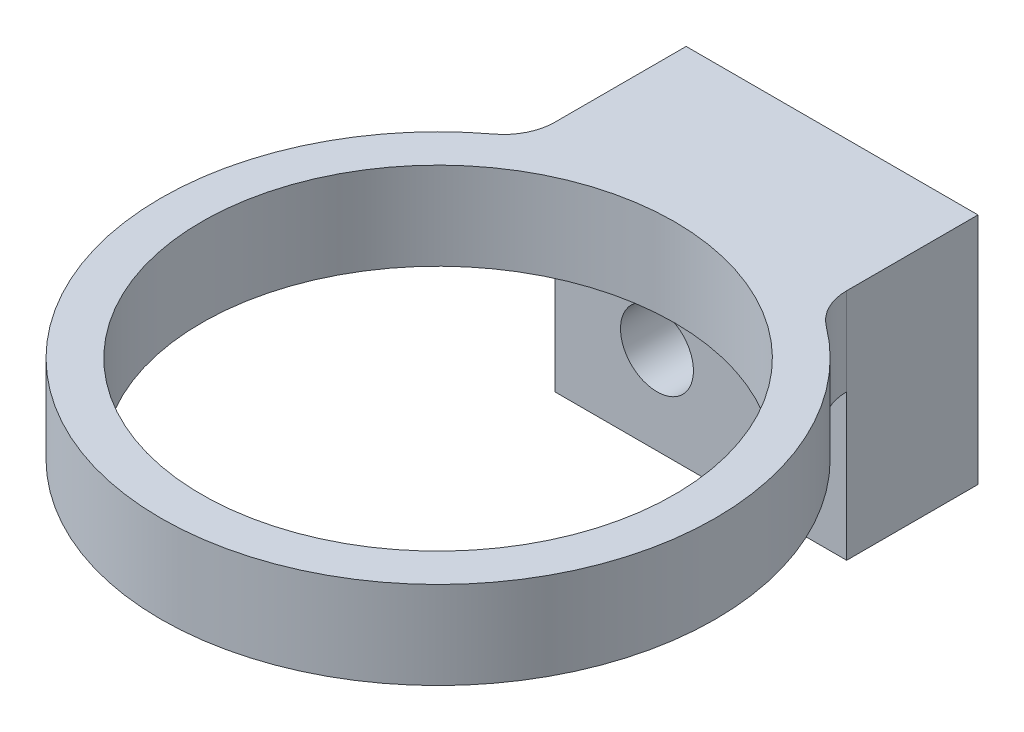
from build123d import *

# Parameters (mm, degrees)
BOSS_EXTRUDE1_DEPTH            = 3
SKETCH2_W                      = 10
SKETCH2_H                      = 4.5
BOSS_EXTRUDE2_DEPTH            = 5
F_1_6_1_6_DIAMETER_HOLE1_D     = 1.6
F_1_6_1_6_DIAMETER_HOLE1_DEPTH = 4
F_1_6_1_6_DIAMETER_HOLE1_TIP   = 0.480688495
F_2_5_2_5_DIAMETER_HOLE1_D     = 2.5
F_2_5_2_5_DIAMETER_HOLE1_DEPTH = 4.5
M14_CLEARANCE_HOLE1_D          = 16.2
M14_CLEARANCE_HOLE1_DEPTH      = 3
FILLET1_R                      = 1.749999932


with BuildPart() as part:
    # Sketch1 → Boss-Extrude1 (new body)
    with BuildSketch(Plane.XZ):
        with BuildLine():
            Line((-5, 5.422252789), (-5, 0))
            Line((-5, 0), (5, 0))
            Line((5, 0), (5, 5.422252789))
            ThreePointArc((5, 5.422252789), (0, 23), (-5, 5.422252789))
        make_face()
    extrude(amount=-BOSS_EXTRUDE1_DEPTH)

    # Sketch2 → Boss-Extrude2 (add)
    with BuildSketch(Plane.XZ):
        with Locations((0, 2.25)):
            Rectangle(SKETCH2_W, SKETCH2_H)
    extrude(amount=BOSS_EXTRUDE2_DEPTH)

    # Ø1.6 (1.6) Diameter Hole1
    with Locations(Plane(origin=(0, 0, 0), x_dir=(-1, 0, 0), z_dir=(0, 0, -1))):
        with Locations((-3, 1)):
            Hole(F_1_6_1_6_DIAMETER_HOLE1_D / 2, depth=F_1_6_1_6_DIAMETER_HOLE1_DEPTH)
            with Locations((0, 0, -(F_1_6_1_6_DIAMETER_HOLE1_DEPTH + F_1_6_1_6_DIAMETER_HOLE1_TIP / 2))):  # 118° drill point
                Cone(0, F_1_6_1_6_DIAMETER_HOLE1_D / 2, F_1_6_1_6_DIAMETER_HOLE1_TIP, mode=Mode.SUBTRACT)

    # Ø2.5 (2.5) Diameter Hole1
    with Locations(Plane.XY.offset(4.5)):
        with Locations((-1.5, -2)):
            Hole(F_2_5_2_5_DIAMETER_HOLE1_D / 2, depth=F_2_5_2_5_DIAMETER_HOLE1_DEPTH)

    # M14 Clearance Hole1
    with Locations(Plane(origin=(0, 0, 0), x_dir=(-1, 0, 0), z_dir=(0, -1, 0))):
        with Locations((0, -13.5)):
            Hole(M14_CLEARANCE_HOLE1_D / 2, depth=M14_CLEARANCE_HOLE1_DEPTH)

    # Fillet1
    fillet1_edges = [part.edges().sort_by_distance(p)[0] for p in [
        (-5, 1.5, 5.422252789),
        (5, 1.5, 5.422252789),
    ]]
    fillet(fillet1_edges, radius=FILLET1_R)


solid = part.part
